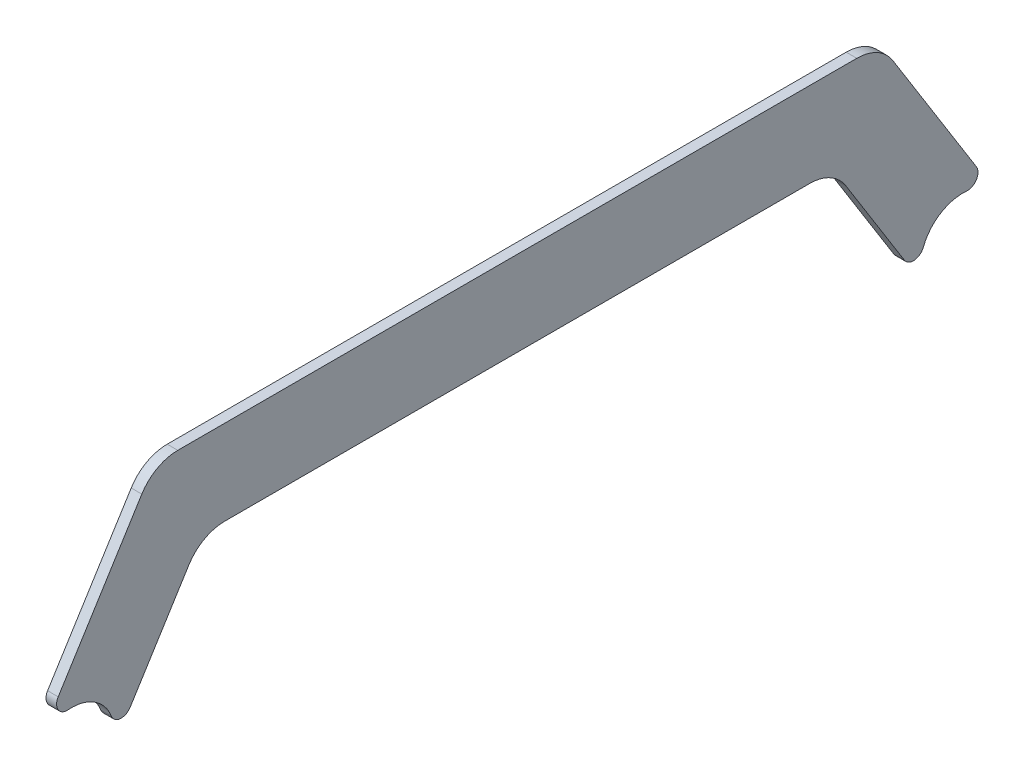
from build123d import *

# Parameters (mm, degrees)
BOSS_EXTRUDE1_DEPTH = 3.175
FILLET1_R           = 3.175
FILLET2_R           = 12.7


with BuildPart() as part:
    # Sketch1 → Boss-Extrude1 (new body)
    with BuildSketch(Plane(origin=(48.385492731365964, 0, 0), x_dir=(0, 0, -1), z_dir=(1, 0, 0))):
        with BuildLine():
            Line((-147.36118847527575, 146.91537779675497), (-111.88055506155092, 203.68439125871458))
            Line((-111.88055506155092, 203.68439125871458), (105.39733503272873, 203.68439125871458))
            Line((105.39733503272873, 203.68439125871458), (140.8779684464535, 146.91537779675497))
            ThreePointArc((140.8779684464535, 146.91537779675497), (123.3774034475485, 150.95396971957916), (119.33881152472429, 133.45340472067417))
            Line((119.33881152472429, 133.45340472067417), (91.31944493844902, 178.28439125871458))
            Line((91.31944493844902, 178.28439125871458), (-97.80266496727123, 178.28439125871458))
            Line((-97.80266496727123, 178.28439125871458), (-125.82203155354657, 133.45340472067417))
            ThreePointArc((-125.82203155354657, 133.45340472067417), (-129.8606234763708, 150.95396971957913), (-147.36118847527575, 146.91537779675497))
        make_face()
    extrude(amount=BOSS_EXTRUDE1_DEPTH)

    # Fillet1
    fillet1_edges = [part.edges().sort_by_distance(p)[0] for p in [
        (49.97299273136596, 146.91537779675497, 147.36118847527575),
        (49.97299273136596, 146.91537779675497, -140.8779684464535),
        (49.97299273136596, 133.45340472067417, -119.33881152472429),
        (49.97299273136596, 133.45340472067417, 125.82203155354657),
    ]]
    fillet(fillet1_edges, radius=FILLET1_R)

    # Fillet2
    fillet2_edges = [part.edges().sort_by_distance(p)[0] for p in [
        (49.97299273136596, 203.68439125871458, 111.88055506155092),
        (49.97299273136596, 203.68439125871458, -105.39733503272873),
        (49.97299273136596, 178.28439125871458, -91.31944493844902),
        (49.97299273136596, 178.28439125871458, 97.80266496727123),
    ]]
    fillet(fillet2_edges, radius=FILLET2_R)


solid = part.part
